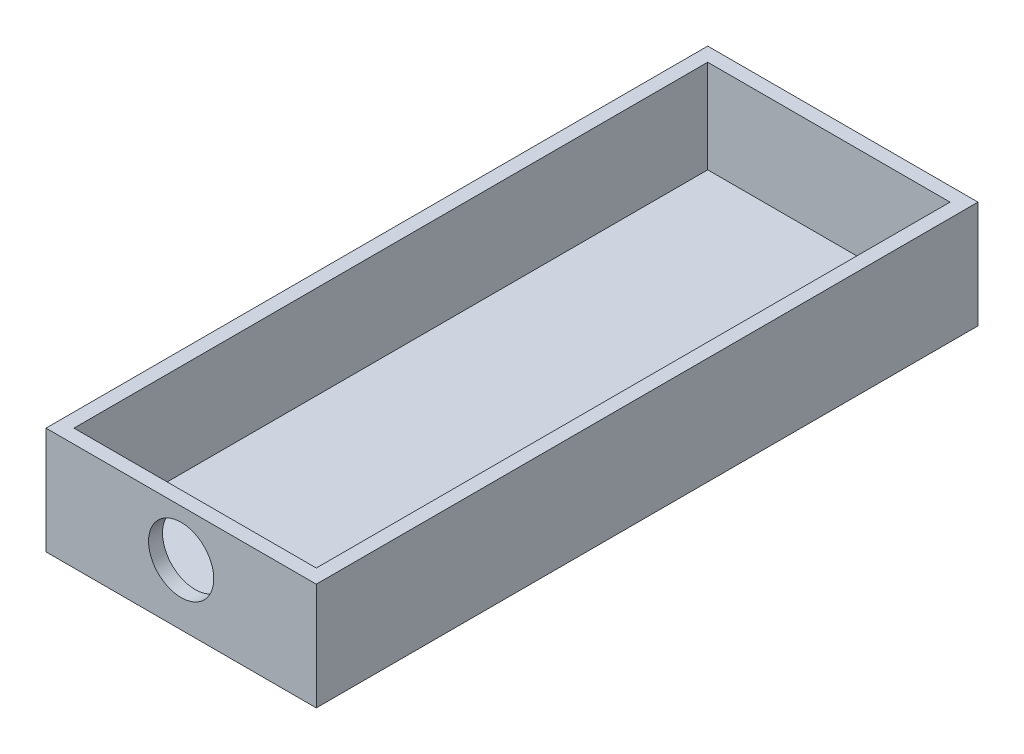
from build123d import *

# Parameters (mm, degrees)
SKETCH1_W           = 29
SKETCH1_H           = 71
BOSS_EXTRUDE1_DEPTH = 1.5
SKETCH2_W           = 29
SKETCH2_H           = 71
SKETCH2_W_2         = 26
SKETCH2_H_2         = 68
BOSS_EXTRUDE2_DEPTH = 10
SKETCH3_R           = 3.5
CUT_EXTRUDE1_DEPTH  = 9


with BuildPart() as part:
    # Sketch1 → Boss-Extrude1 (new body)
    with BuildSketch(Plane(origin=(0, 0, 0), x_dir=(1, 0, 0), z_dir=(0, 1, 0))):
        with Locations((14.5, 35.5)):
            Rectangle(SKETCH1_W, SKETCH1_H)
    extrude(amount=BOSS_EXTRUDE1_DEPTH)

    # Sketch2 → Boss-Extrude2 (add)
    with BuildSketch(Plane(origin=(0, 1.5, 0), x_dir=(1, 0, 0), z_dir=(0, 1, 0))):
        with Locations((14.5, 35.5)):
            Rectangle(SKETCH2_W, SKETCH2_H)
        with Locations((14.5, 35.5)):
            Rectangle(SKETCH2_W_2, SKETCH2_H_2, mode=Mode.SUBTRACT)
    extrude(amount=BOSS_EXTRUDE2_DEPTH)

    # Sketch3 → Cut-Extrude1 (cut)
    with BuildSketch(Plane(origin=(0, 0, -1.5), x_dir=(-1, 0, 0), z_dir=(0, 0, -1))):
        with Locations((-14.5, 6.5)):
            Circle(SKETCH3_R)
    extrude(amount=-CUT_EXTRUDE1_DEPTH, mode=Mode.SUBTRACT)


solid = part.part
